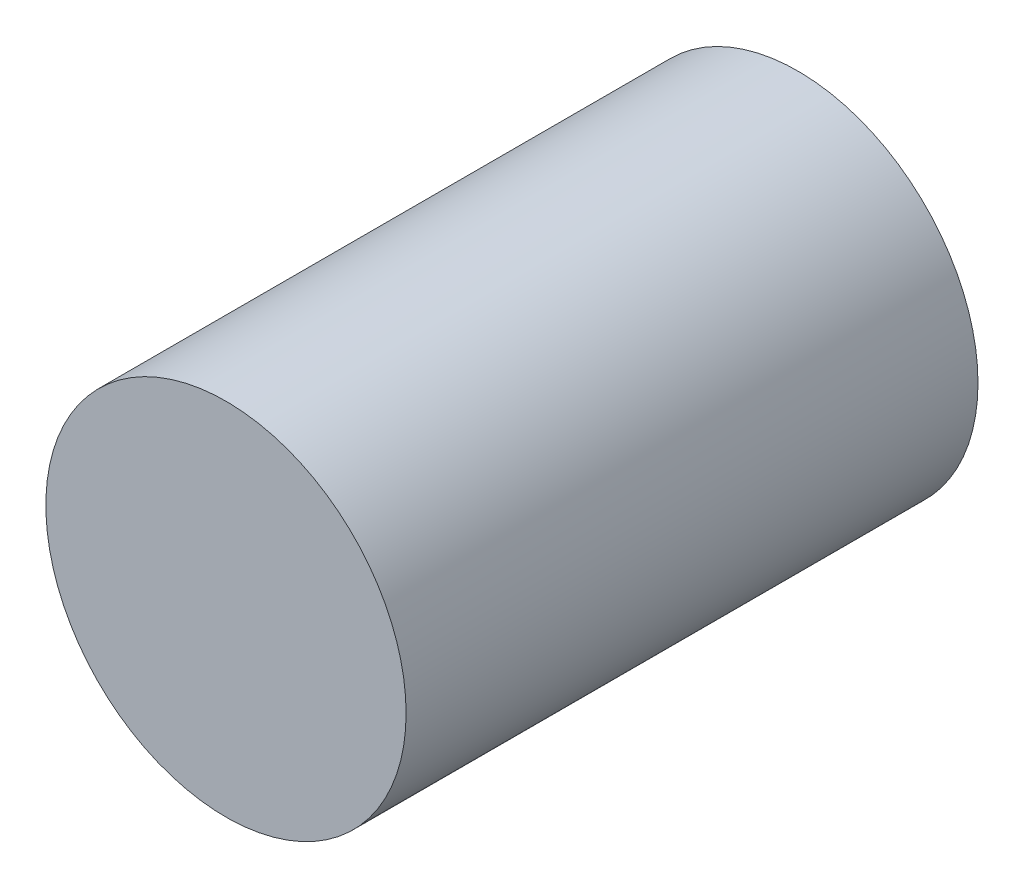
from build123d import *

# Parameters (mm, degrees)
SKETCH1_R           = 1
BOSS_EXTRUDE1_DEPTH = 3.175


with BuildPart() as part:
    # Sketch1 → Boss-Extrude1 (new body)
    with BuildSketch(Plane.XY):
        Circle(SKETCH1_R)
    extrude(amount=BOSS_EXTRUDE1_DEPTH)


solid = part.part
